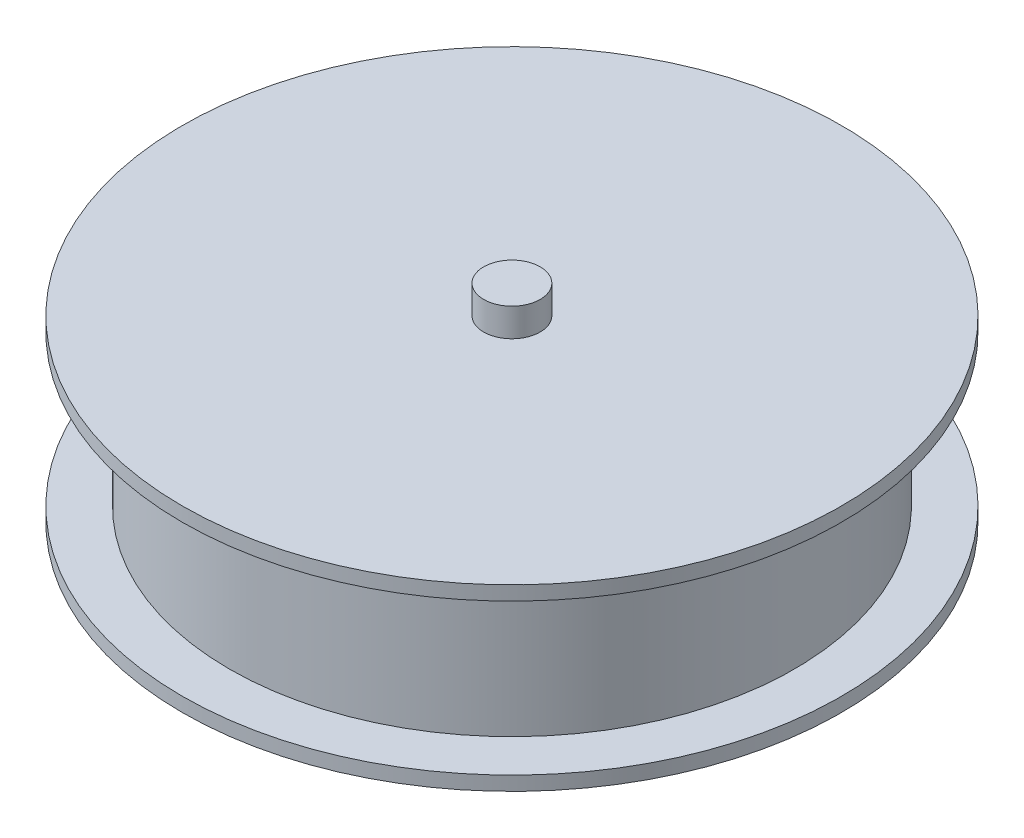
from build123d import *

# Parameters (mm, degrees)
SKETCH1_R           = 35
BOSS_EXTRUDE1_DEPTH = 1.5
SKETCH2_R           = 30
BOSS_EXTRUDE3_DEPTH = 8
SKETCH3_R           = 3
CUT_EXTRUDE1_DEPTH  = 80
SKETCH6_R           = 3
BOSS_EXTRUDE5_DEPTH = 3


with BuildPart() as part:
    # Sketch1 → Boss-Extrude1 (new body)
    with BuildSketch(Plane(origin=(0, 0, 0), x_dir=(1, 0, 0), z_dir=(0, 1, 0))):
        Circle(SKETCH1_R)
    extrude(amount=BOSS_EXTRUDE1_DEPTH)

    # Sketch2 → Boss-Extrude3 (add)
    with BuildSketch(Plane(origin=(0, 1.5, 0), x_dir=(1, 0, 0), z_dir=(0, 1, 0))):
        Circle(SKETCH2_R)
    extrude(amount=BOSS_EXTRUDE3_DEPTH)

    # Mirror1: part across plane


with BuildPart() as part_1:
    add(part.part)
    add(part.part.mirror(Plane.ZX.offset(9.5)))

    # Sketch3 → Cut-Extrude1 (cut)
    with BuildSketch(Plane(origin=(0, 19, 0), x_dir=(1, 0, 0), z_dir=(0, 1, 0))):
        Circle(SKETCH3_R)
    extrude(amount=-CUT_EXTRUDE1_DEPTH, mode=Mode.SUBTRACT)


with BuildPart() as body_2:
    # Sketch6 → Boss-Extrude5 (new body)
    with BuildSketch(Plane(origin=(0, 19, 0), x_dir=(1, 0, 0), z_dir=(0, 1, 0))):
        Circle(SKETCH6_R)
    extrude(amount=BOSS_EXTRUDE5_DEPTH)


solid = Compound([part_1.part, body_2.part])
